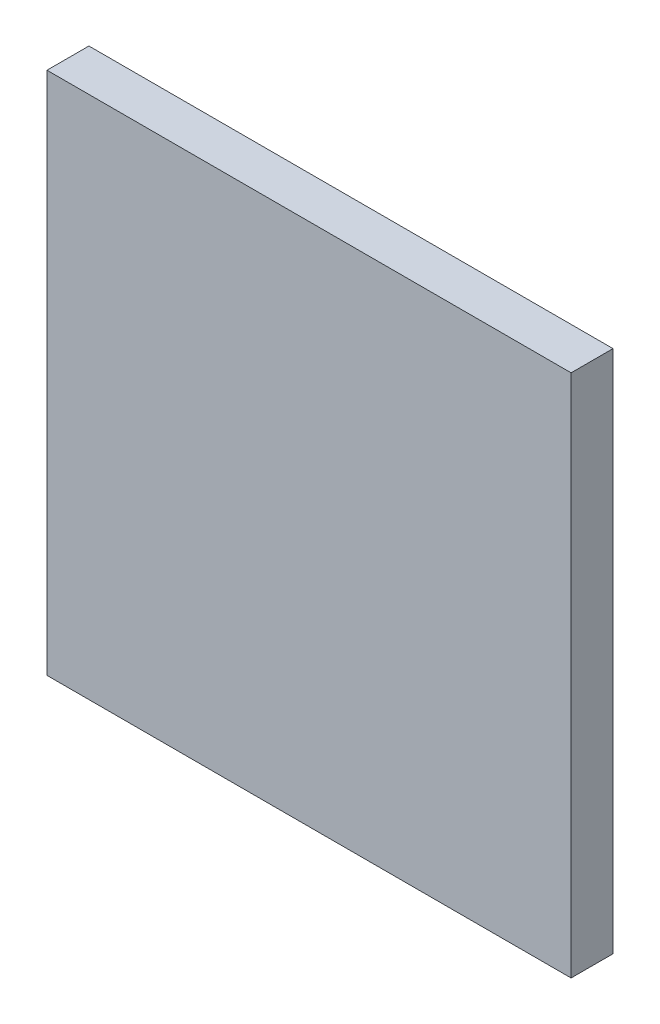
from build123d import *

# Parameters (mm, degrees)
EXTRUDE_1_DEPTH = 2


with BuildPart() as part:
    # 草图1 → 凸台-拉伸1 (new body)
    with BuildSketch(Plane.XY):
        Polygon((208.308771729, 77.293179349), (208.308771729, 89.793179349), (233.308771729, 89.793179349), (233.308771729, 64.793179349), (208.308771729, 64.793179349), align=None)
    extrude(amount=EXTRUDE_1_DEPTH)


solid = part.part
